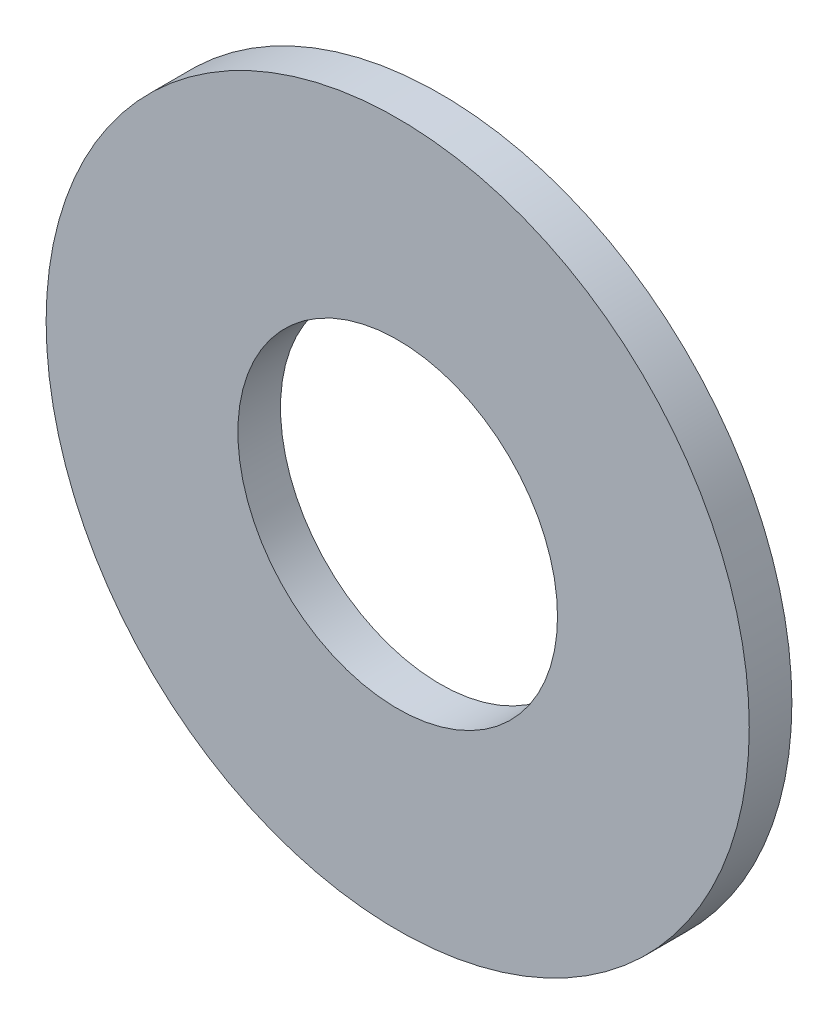
from build123d import *

# Parameters (mm, degrees)
SKETCH1_R           = 82.5
SKETCH1_R_2         = 37.5
BOSS_EXTRUDE1_DEPTH = 10


with BuildPart() as part:
    # Sketch1 → Boss-Extrude1 (new body)
    with BuildSketch(Plane.XY):
        Circle(SKETCH1_R)
        Circle(SKETCH1_R_2, mode=Mode.SUBTRACT)
    extrude(amount=BOSS_EXTRUDE1_DEPTH)


solid = part.part
